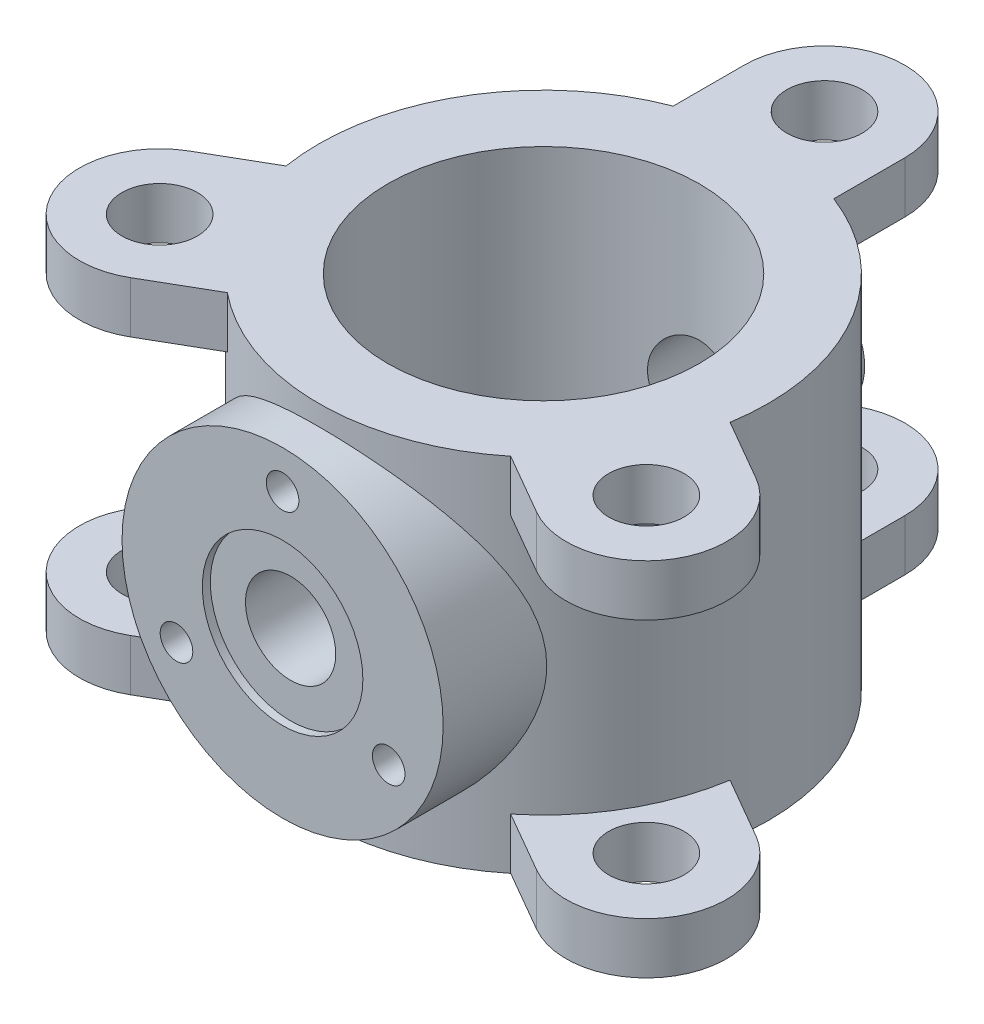
from build123d import *

# Parameters (mm, degrees)
SKETCH1_R                = 140
SKETCH1_R_2              = 97
BOSS_EXTRUDE1_DEPTH      = 112.5
BOSS_EXTRUDE2_REACH      = 353.799
BOSS_EXTRUDE2_END_RADIUS = 140
SKETCH2_R                = 100
BOSS_EXTRUDE3_REACH      = 373.324
BOSS_EXTRUDE3_END_RADIUS = 140
SKETCH3_R                = 37.5
HOLE1_D                  = 20.3
HOLE1_DEPTH              = 30
CIRPATTERN2_COUNT        = 3
HOLE2_D                  = 56.2
HOLE2_DEPTH              = 310
HOLE2_CBORE_D            = 100
HOLE2_CBORE_DEPTH        = 5
BOSS_EXTRUDE6_DEPTH      = 32
CIRPATTERN5_COUNT        = 3
SKETCH16_W               = 23.5
SKETCH16_H               = 32
HOLE3_AT_2_COUNT         = 2
HOLE3_AT_2_PITCH         = 303.108891325
HOLE3_AT_3_COUNT         = 2
HOLE3_AT_3_PITCH         = 303.108891325
MIRROR1_COPY_1_DEPTH     = 32
MIRROR1_COPY_2_DEPTH     = 32
MIRROR1_COPY_3_SKETCH_W  = 23.5
MIRROR1_COPY_3_SKETCH_H  = 32
MIRROR1_COPY_4_SKETCH_W  = 23.5
MIRROR1_COPY_4_SKETCH_H  = 32


with BuildPart() as part:
    # Sketch1 → Boss-Extrude1 (new, symmetric)
    with BuildSketch(Plane(origin=(0, 0, 0), x_dir=(1, 0, 0), z_dir=(0, 1, 0))):
        with Locations(Location((0, 0, 0), (0, 0, 270))):
            Circle(SKETCH1_R)
        with Locations(Location((0, 0, 0), (0, 0, 270))):
            Circle(SKETCH1_R_2, mode=Mode.SUBTRACT)
    extrude(amount=BOSS_EXTRUDE1_DEPTH, both=True)

    # Boss-Extrude2: up to this cylinder (the profile starts outside it)
    boss_extrude2_end = Plane(origin=(0, 0, 0), z_dir=(0, -1, 0)) * Cylinder(BOSS_EXTRUDE2_END_RADIUS, 988.598, mode=Mode.PRIVATE)
    # Sketch2 → Boss-Extrude2 (add, up to the surface)
    with BuildSketch(Plane.XY.offset(162.5), mode=Mode.PRIVATE) as boss_extrude2_sk1:
        Circle(SKETCH2_R)
    boss_extrude2_tool1 = extrude(boss_extrude2_sk1.sketch, amount=-BOSS_EXTRUDE2_REACH, mode=Mode.PRIVATE) - boss_extrude2_end
    add(boss_extrude2_tool1.solids().sort_by_distance((0, 0, 162.5))[0])

    # Boss-Extrude3: up to this cylinder (the profile starts outside it)
    boss_extrude3_end = Plane(origin=(0, 0, 0), z_dir=(0, -1, 0)) * Cylinder(BOSS_EXTRUDE3_END_RADIUS, 1027.648, mode=Mode.PRIVATE)
    # Sketch3 → Boss-Extrude3 (add, up to the surface)
    with BuildSketch(Plane.XY.offset(-162.5), mode=Mode.PRIVATE) as boss_extrude3_sk1:
        with Locations(Location((0, 0, 0), (0, 0, 90))):
            Circle(SKETCH3_R)
    boss_extrude3_tool1 = extrude(boss_extrude3_sk1.sketch, amount=BOSS_EXTRUDE3_REACH, mode=Mode.PRIVATE) - boss_extrude3_end
    add(boss_extrude3_tool1.solids().sort_by_distance((0, 0, -162.5))[0])

    # Hole1
    with Locations(Plane.XY.offset(162.5)):
        with Locations((0, 76.3)):
            hole1 = Hole(HOLE1_D / 2, depth=HOLE1_DEPTH)

    # CirPattern2: Hole1 ×3 about axis
    cirpattern2_axis = Axis((0, 0, 0), (0, 0, 1))
    for i in range(1, CIRPATTERN2_COUNT):
        add(hole1.rotate(cirpattern2_axis, i * 360 / CIRPATTERN2_COUNT), mode=Mode.SUBTRACT)

    # Hole2
    with Locations(Plane.XY.offset(162.5)):
        with Locations((0, 0)):
            CounterBoreHole(HOLE2_D / 2, HOLE2_CBORE_D / 2, HOLE2_CBORE_DEPTH, depth=HOLE2_DEPTH)

    # Sketch10 → Boss-Extrude6 (add)
    with BuildSketch(Plane(origin=(0, 112.5, 0), x_dir=(1, 0, 0), z_dir=(0, 1, 0))):
        with BuildLine():
            Line((50, 130.766968306), (50, 175))
            ThreePointArc((50, 175), (0, 225), (-50, 175))
            Line((-50, 175), (-50, 130.766968306))
            ThreePointArc((-50, 130.766968306), (0, 140), (50, 130.766968306))
        make_face()
    boss_extrude6 = extrude(amount=-BOSS_EXTRUDE6_DEPTH)

    # CirPattern5: Boss-Extrude6 ×3 about axis
    cirpattern5_axis = Axis((0, 0, 0), (0, 1, 0))
    for i in range(1, CIRPATTERN5_COUNT):
        add(boss_extrude6.rotate(cirpattern5_axis, i * 360 / CIRPATTERN5_COUNT))

    # Sketch16 → Hole3 (revolve, cut)
    with BuildSketch(Plane(origin=(0, 112.5, -175), x_dir=(0, 0, 1), z_dir=(1, 0, 0))):
        with Locations((11.75, 16)):
            Rectangle(SKETCH16_W, SKETCH16_H)
    hole3 = revolve(axis=Axis((0, 2.5, -175), (0, 1, 0)), mode=Mode.SUBTRACT)

    # Hole3 at 2: Hole3 ×2
    with Locations(*[Vector(0.500000000000004, 0, 0.8660254037844364) * (i * HOLE3_AT_2_PITCH) for i in range(1, HOLE3_AT_2_COUNT)]):
        add(hole3, mode=Mode.SUBTRACT)

    # Hole3 at 3: Hole3 ×2
    with Locations(*[Vector(-0.49999999999999806, 0, 0.8660254037844397) * (i * HOLE3_AT_3_PITCH) for i in range(1, HOLE3_AT_3_COUNT)]):
        add(hole3, mode=Mode.SUBTRACT)

    # Mirror1: Boss-Extrude6, Hole3 across plane
    add(boss_extrude6.mirror(Plane.ZX))
    add(hole3.mirror(Plane.ZX), mode=Mode.SUBTRACT)

    # Mirror1 copy 1 sketch → Mirror1 copy 1 (add)
    with BuildSketch(Plane(origin=(0, -112.5, 0), x_dir=(-0.4999999999999998, 0, -0.8660254037844387), z_dir=(0, -1, 0))):
        with BuildLine():
            Line((50, -130.766968306), (50, -175))
            ThreePointArc((50, -175), (0, -225), (-50, -175))
            Line((-50, -175), (-50, -130.766968306))
            ThreePointArc((-50, -130.766968306), (0, -140), (50, -130.766968306))
        make_face()
    extrude(amount=-MIRROR1_COPY_1_DEPTH)

    # Mirror1 copy 2 sketch → Mirror1 copy 2 (add)
    with BuildSketch(Plane(origin=(0, -112.5, 0), x_dir=(-0.5000000000000004, 0, 0.8660254037844384), z_dir=(0, -1, 0))):
        with BuildLine():
            Line((50, -130.766968306), (50, -175))
            ThreePointArc((50, -175), (0, -225), (-50, -175))
            Line((-50, -175), (-50, -130.766968306))
            ThreePointArc((-50, -130.766968306), (0, -140), (50, -130.766968306))
        make_face()
    extrude(amount=-MIRROR1_COPY_2_DEPTH)

    # Mirror1 copy 3 sketch → Mirror1 copy 3 (revolve, cut)
    with BuildSketch(Plane(origin=(151.554445662, -112.5, 87.5), x_dir=(0, 0, 1), z_dir=(1, 0, 0))):
        with Locations((11.75, -16)):
            Rectangle(MIRROR1_COPY_3_SKETCH_W, MIRROR1_COPY_3_SKETCH_H)
    revolve(axis=Axis((151.554445662, -2.5, 87.5), (0, 1, 0)), mode=Mode.SUBTRACT)

    # Mirror1 copy 4 sketch → Mirror1 copy 4 (revolve, cut)
    with BuildSketch(Plane(origin=(-151.554445662, -112.5, 87.5), x_dir=(0, 0, 1), z_dir=(1, 0, 0))):
        with Locations((11.75, -16)):
            Rectangle(MIRROR1_COPY_4_SKETCH_W, MIRROR1_COPY_4_SKETCH_H)
    revolve(axis=Axis((-151.554445662, -2.5, 87.5), (0, 1, 0)), mode=Mode.SUBTRACT)


solid = part.part
